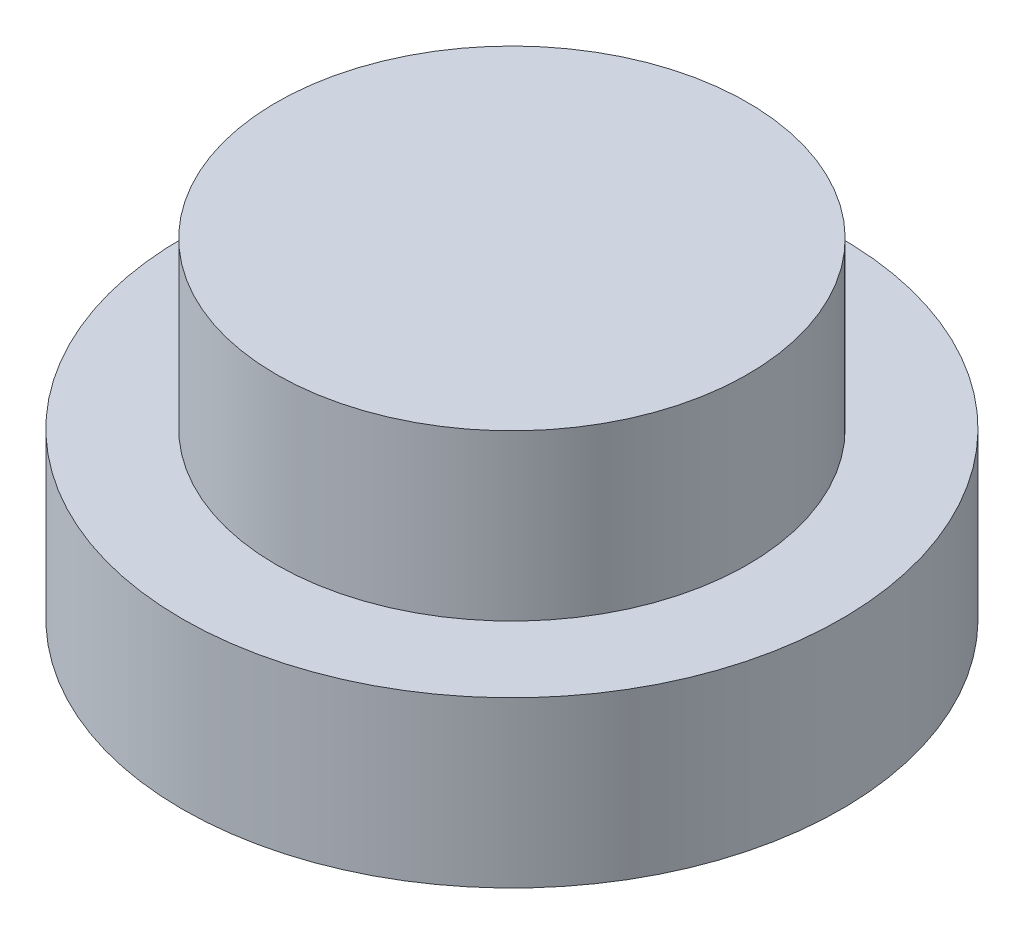
from build123d import *

# Parameters (mm, degrees)
SKETCH1_R           = 2
BOSS_EXTRUDE1_DEPTH = 1
SKETCH2_R           = 1.43
BOSS_EXTRUDE2_DEPTH = 1


with BuildPart() as part:
    # Sketch1 → Boss-Extrude1 (new body)
    with BuildSketch(Plane(origin=(0, 0, 0), x_dir=(1, 0, 0), z_dir=(0, 1, 0))):
        Circle(SKETCH1_R)
    extrude(amount=BOSS_EXTRUDE1_DEPTH)

    # Sketch2 → Boss-Extrude2 (add)
    with BuildSketch(Plane(origin=(0, 1, 0), x_dir=(1, 0, 0), z_dir=(0, 1, 0))):
        Circle(SKETCH2_R)
    extrude(amount=BOSS_EXTRUDE2_DEPTH)


solid = part.part
